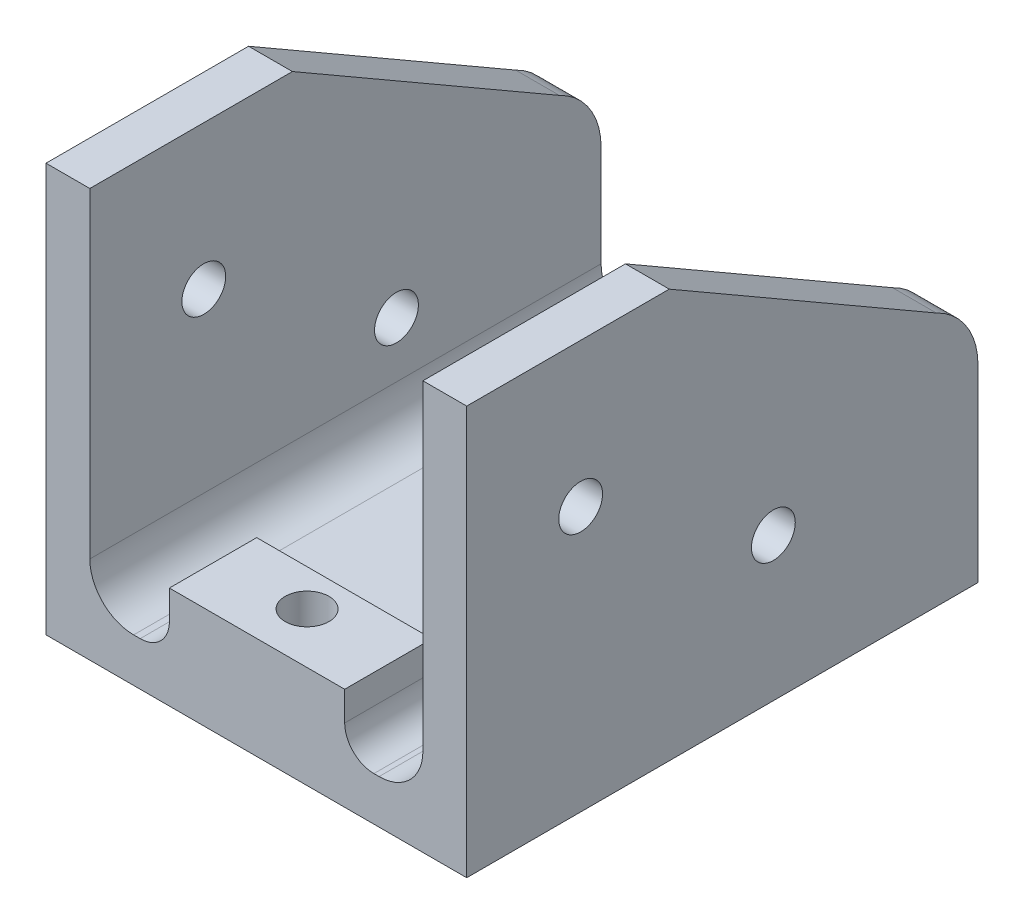
from build123d import *

# Parameters (mm, degrees)
EXTRUDE_1_DEPTH     = 35
SKETCH_7_W          = 12
SKETCH_7_H          = 6.5
EXTRUDE_3_DEPTH     = 4
CUT_EXTRUDE_1_REACH = 5
SKETCH_2_R          = 1.5
CUT_EXTRUDE_2_DEPTH = 28.8
SKETCH_6_W          = 12
SKETCH_6_H          = 5.977376498
SKETCH_6_R          = 1.5
EXTRUDE_2_DEPTH     = 4
CUT_EXTRUDE_3_REACH = 29.964
SKETCH_9_R          = 1.5
FILLET_1_R          = 3
FILLET_2_R          = 2
MM_CLEARANCE_1_D    = 3


with BuildPart() as part:
    # 草图1 → 凸台-拉伸1 (new body)
    with BuildSketch(Plane.XY):
        Polygon((-25.8, 21.661752689), (-25.8, -6.245255474), (3, -6.245255474), (3, 21.718248175), (0, 21.718248175), (0, -3.245255474), (-22.8, -3.245255474), (-22.8, 21.718248175), (-25.8, 21.718248175), align=None)
    extrude(amount=EXTRUDE_1_DEPTH)

    # 草图7 → 凸台-拉伸3 (add)
    with BuildSketch(Plane(origin=(0, -3.245255474, 0), x_dir=(1, 0, 0), z_dir=(0, 1, 0))):
        with Locations((-11.4, -3.272623502)):
            Rectangle(SKETCH_7_W, SKETCH_7_H)
    extrude(amount=EXTRUDE_3_DEPTH)

    # 草图2 → 切除-拉伸1 (cut, up to next)
    with BuildSketch(Plane(origin=(0, -3.245255474, 0), x_dir=(1, 0, 0), z_dir=(0, 1, 0)), mode=Mode.PRIVATE) as cut_extrude_1_sk1:
        with Locations((-11.4, -4.329564509)):
            Circle(SKETCH_2_R)
    cut_extrude_1_tool1 = extrude(cut_extrude_1_sk1.sketch, amount=-CUT_EXTRUDE_1_REACH, mode=Mode.PRIVATE) & part.part
    add(cut_extrude_1_tool1.solids().sort_by_distance((-11.4, -3.245255, 4.329565))[0], mode=Mode.SUBTRACT)
    # 草图2 → 切除-拉伸1 (cut, up to next)
    with BuildSketch(Plane(origin=(0, -3.245255474, 0), x_dir=(1, 0, 0), z_dir=(0, 1, 0)), mode=Mode.PRIVATE) as cut_extrude_1_sk2:
        with Locations((-11.4, -31.529564509)):
            Circle(SKETCH_2_R)
    cut_extrude_1_tool2 = extrude(cut_extrude_1_sk2.sketch, amount=-CUT_EXTRUDE_1_REACH, mode=Mode.PRIVATE) & part.part
    add(cut_extrude_1_tool2.solids().sort_by_distance((-11.4, -3.245255, 31.529565))[0], mode=Mode.SUBTRACT)
    # 草图2 → 切除-拉伸1 (cut, up to next)
    with BuildSketch(Plane(origin=(0, -3.245255474, 0), x_dir=(1, 0, 0), z_dir=(0, 1, 0)), mode=Mode.PRIVATE) as cut_extrude_1_sk3:
        with BuildLine():
            Line((-14.65, -18), (-14.65, -16.99341649))
            ThreePointArc((-14.65, -16.99341649), (-11.4, -6.5), (-8.15, -16.99341649))
            Line((-8.15, -16.99341649), (-8.15, -18))
            ThreePointArc((-8.15, -18), (-11.4, -21.25), (-14.65, -18))
        make_face()
    cut_extrude_1_tool3 = extrude(cut_extrude_1_sk3.sketch, amount=-CUT_EXTRUDE_1_REACH, mode=Mode.PRIVATE) & part.part
    add(cut_extrude_1_tool3.solids().sort_by_distance((-11.4, -3.245255, 13.308508))[0], mode=Mode.SUBTRACT)

    # 草图5 → 切除-拉伸2 (cut)
    with BuildSketch(Plane.ZY.offset(25.8)):
        with BuildLine():
            Line((0, 6.647160947), (0, 21.718248175))
            Line((0, 21.718248175), (21.134010141, 21.718248175))
            Line((21.134010141, 21.718248175), (2.843364957, 11.158139254))
            ThreePointArc((2.843364957, 11.158139254), (0.770155132, 9.313321556), (0, 6.647160947))
        make_face()
    extrude(amount=-CUT_EXTRUDE_2_DEPTH, mode=Mode.SUBTRACT)

    # 草图6 → 凸台-拉伸2 (add)
    with BuildSketch(Plane(origin=(0, -3.245255474, 0), x_dir=(1, 0, 0), z_dir=(0, 1, 0))):
        with Locations((-11.353661672, -32.011311751)):
            Rectangle(SKETCH_6_W, SKETCH_6_H)
        with Locations((-11.4, -31.529564509)):
            Circle(SKETCH_6_R, mode=Mode.SUBTRACT)
    extrude(amount=EXTRUDE_2_DEPTH)

    # 草图9 → 切除-拉伸3 (cut, up to next)
    with BuildSketch(Plane.XZ.offset(6.245255474), mode=Mode.PRIVATE) as cut_extrude_3_sk1:
        with Locations((-11.4, 4.329564509)):
            Circle(SKETCH_9_R)
    cut_extrude_3_tool1 = extrude(cut_extrude_3_sk1.sketch, amount=-CUT_EXTRUDE_3_REACH, mode=Mode.PRIVATE) & part.part
    add(cut_extrude_3_tool1.solids().sort_by_distance((-11.4, -6.245255, 4.329565))[0], mode=Mode.SUBTRACT)

    # 圆角1
    fillet_1_edges = [part.edges().sort_by_distance(p)[0] for p in [
        (-22.8, -3.245255474, 17.5),
        (0, -3.245255474, 17.5),
    ]]
    fillet(fillet_1_edges, radius=FILLET_1_R)

    # 圆角2
    fillet_2_edges = [part.edges().sort_by_distance(p)[0] for p in [
        (-5.4, -3.245255474, 3.272623502),
        (-17.4, -3.245255474, 3.272623502),
        (-5.353661672, -3.245255474, 32.011311751),
        (-17.353661672, -3.245255474, 32.011311751),
    ]]
    fillet(fillet_2_edges, radius=FILLET_2_R)

    # 大小mm Clearance 暗销孔1 (through all)
    with Locations(Plane(origin=(3, -125.31519419, 113.107396439), x_dir=(0, 0.022253058, -0.99975237), z_dir=(1, 0, 0))):
        with Locations((88.938953066, 135.227377046), (101.942467158, 126.647536361), (127.53759353, 125.598807912), (135.454300746, 124.4473971)):
            Hole(MM_CLEARANCE_1_D / 2)


solid = part.part
